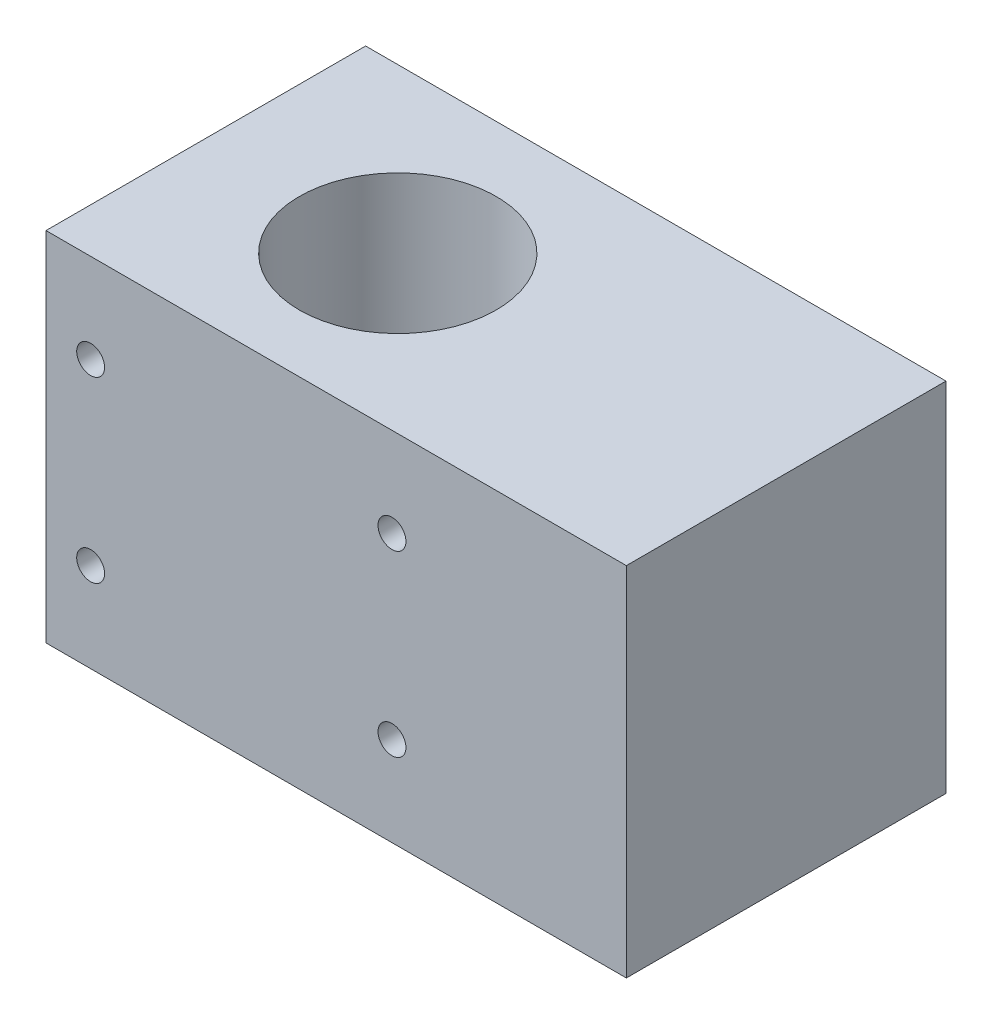
from build123d import *

# Parameters (mm, degrees)
SKETCH1_W                                = 82.55
SKETCH1_H                                = 50.8
BOSS_EXTRUDE1_DEPTH                      = 45.466
SKETCH2_R                                = 14
CUT_EXTRUDE1_DEPTH                       = 51.8
F_5_32_0_15625_DIAMETER_HOLE1_AT_2_COUNT = 2
F_5_32_0_15625_DIAMETER_HOLE1_AT_2_PITCH = 42.8625
F_5_32_0_15625_DIAMETER_HOLE1_AT_3_COUNT = 2
F_5_32_0_15625_DIAMETER_HOLE1_AT_3_PITCH = 49.823226574
F_5_32_0_15625_DIAMETER_HOLE1_AT_4_COUNT = 2
F_5_32_0_15625_DIAMETER_HOLE1_AT_4_PITCH = 25.4
TAP_DRILL_FOR_3_8_24_TAP2_D              = 8.4328
TAP_DRILL_FOR_3_8_24_TAP2_DEPTH          = 31.75
TAP_DRILL_FOR_3_8_24_TAP2_TIP            = 2.533468714


with BuildPart() as part:
    # Sketch1 → Boss-Extrude1 (new body)
    with BuildSketch(Plane.XY):
        with Locations((41.275, 25.4)):
            Rectangle(SKETCH1_W, SKETCH1_H)
    extrude(amount=BOSS_EXTRUDE1_DEPTH)

    # Sketch2 → Cut-Extrude1 (cut, through all)
    with BuildSketch(Plane(origin=(0, 50.8, 0), x_dir=(1, 0, 0), z_dir=(0, 1, 0))):
        with Locations((27.813, -23.241)):
            Circle(SKETCH2_R)
    extrude(amount=-CUT_EXTRUDE1_DEPTH, mode=Mode.SUBTRACT)

    # Sketch6 → 5/32 (0.15625) Diameter Hole1 (revolve, cut)
    with BuildSketch(Plane(origin=(6.35, 38.1, 45.466), x_dir=(0, -1, 0), z_dir=(1, 0, 0))):
        Polygon((0, 0), (0, 13.892332791), (1.984375, 12.7), (1.984375, 0), align=None)
    f_5_32_0_15625_diameter_hole1 = revolve(axis=Axis((6.35, 38.1, 51.816), (0, 0, -1)), mode=Mode.SUBTRACT)

    # 5/32 (0.15625) Diameter Hole1 at 2: 5/32 (0.15625) Diameter Hole1 ×2
    with Locations(*[(i * F_5_32_0_15625_DIAMETER_HOLE1_AT_2_PITCH, 0, 0) for i in range(1, F_5_32_0_15625_DIAMETER_HOLE1_AT_2_COUNT)]):
        add(f_5_32_0_15625_diameter_hole1, mode=Mode.SUBTRACT)

    # 5/32 (0.15625) Diameter Hole1 at 3: 5/32 (0.15625) Diameter Hole1 ×2
    with Locations(*[Vector(0.860291534, -0.50980239, 0) * (i * F_5_32_0_15625_DIAMETER_HOLE1_AT_3_PITCH) for i in range(1, F_5_32_0_15625_DIAMETER_HOLE1_AT_3_COUNT)]):
        add(f_5_32_0_15625_diameter_hole1, mode=Mode.SUBTRACT)

    # 5/32 (0.15625) Diameter Hole1 at 4: 5/32 (0.15625) Diameter Hole1 ×2
    with Locations(*[(0, -i * F_5_32_0_15625_DIAMETER_HOLE1_AT_4_PITCH, 0) for i in range(1, F_5_32_0_15625_DIAMETER_HOLE1_AT_4_COUNT)]):
        add(f_5_32_0_15625_diameter_hole1, mode=Mode.SUBTRACT)

    # Mirror1: 5/32 (0.15625) Diameter Hole1 across plane
    add(f_5_32_0_15625_diameter_hole1.mirror(Plane.XY.offset(22.733)), mode=Mode.SUBTRACT)

    # Mirror1 copy 1 sketch → Mirror1 copy 1 (revolve, cut)
    with BuildSketch(Plane(origin=(49.2125, 38.1, 0), x_dir=(0, -1, 0), z_dir=(1, 0, 0))):
        Polygon((0, 0), (0, -13.892332791), (1.984375, -12.7), (1.984375, 0), align=None)
    revolve(axis=Axis((49.2125, 38.1, -6.35), (0, 0, -1)), mode=Mode.SUBTRACT)

    # Mirror1 copy 2 sketch → Mirror1 copy 2 (revolve, cut)
    with BuildSketch(Plane(origin=(49.2125, 12.7, 0), x_dir=(0, -1, 0), z_dir=(1, 0, 0))):
        Polygon((0, 0), (0, -13.892332791), (1.984375, -12.7), (1.984375, 0), align=None)
    revolve(axis=Axis((49.2125, 12.7, -6.35), (0, 0, -1)), mode=Mode.SUBTRACT)

    # Mirror1 copy 3 sketch → Mirror1 copy 3 (revolve, cut)
    with BuildSketch(Plane(origin=(6.35, 12.7, 0), x_dir=(0, -1, 0), z_dir=(1, 0, 0))):
        Polygon((0, 0), (0, -13.892332791), (1.984375, -12.7), (1.984375, 0), align=None)
    revolve(axis=Axis((6.35, 12.7, -6.35), (0, 0, -1)), mode=Mode.SUBTRACT)

    # Tap Drill for 3/8-24 Tap2
    with Locations(Plane(origin=(0, 0, 0), x_dir=(-1, 0, 0), z_dir=(0, -1, 0))):
        with Locations((-74.295, -23.241)):
            Hole(TAP_DRILL_FOR_3_8_24_TAP2_D / 2, depth=TAP_DRILL_FOR_3_8_24_TAP2_DEPTH)
            with Locations((0, 0, -(TAP_DRILL_FOR_3_8_24_TAP2_DEPTH + TAP_DRILL_FOR_3_8_24_TAP2_TIP / 2))):  # 118° drill point
                Cone(0, TAP_DRILL_FOR_3_8_24_TAP2_D / 2, TAP_DRILL_FOR_3_8_24_TAP2_TIP, mode=Mode.SUBTRACT)


solid = part.part
